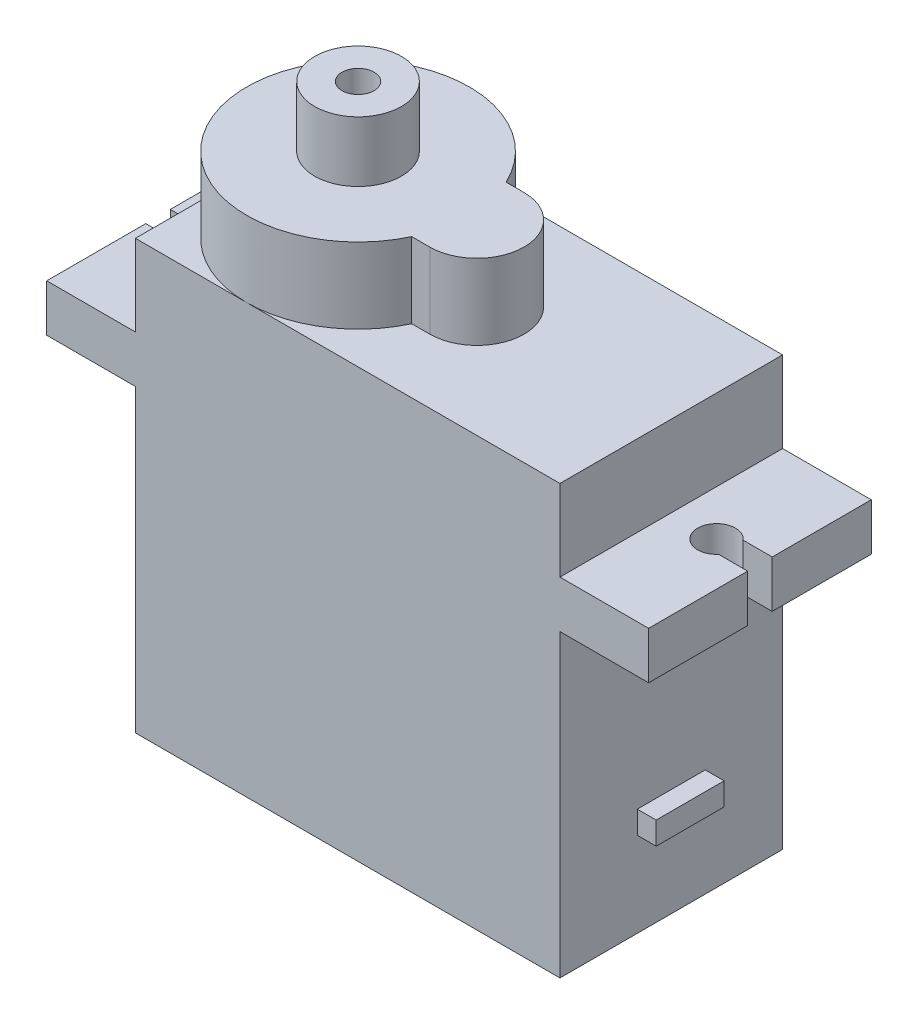
from build123d import *

# Parameters (mm, degrees)
SKETCH1_W           = 22.5
SKETCH1_H           = 11.8
BOSS_EXTRUDE1_DEPTH = 22.7
BOSS_EXTRUDE2_START = 15.9
BOSS_EXTRUDE2_DEPTH = 2.5
BOSS_EXTRUDE3_DEPTH = 4
SKETCH4_R           = 2.3
SKETCH4_R_2         = 0.85
BOSS_EXTRUDE4_DEPTH = 3.2
SKETCH5_W           = 3.6
SKETCH5_H           = 1.2
BOSS_EXTRUDE5_DEPTH = 1


with BuildPart() as part:
    # Sketch1 → Boss-Extrude1 (new body)
    with BuildSketch(Plane(origin=(0, 0, 0), x_dir=(1, 0, 0), z_dir=(0, 1, 0))):
        Rectangle(SKETCH1_W, SKETCH1_H)
    extrude(amount=BOSS_EXTRUDE1_DEPTH)

    # Sketch2 → Boss-Extrude2 (add)
    with BuildSketch(Plane(origin=(0, 0, 0), x_dir=(1, 0, 0), z_dir=(0, 1, 0)).offset(BOSS_EXTRUDE2_START)):
        with BuildLine():
            Line((15.95, 5.9), (11.25, 5.9))
            Line((11.25, 5.9), (11.25, -5.9))
            Line((11.25, -5.9), (15.95, -5.9))
            Line((15.95, -5.9), (15.95, -0.65))
            Line((15.95, -0.65), (14.409934208, -0.65))
            ThreePointArc((14.409934208, -0.65), (12.65, 0), (14.409934208, 0.65))
            Line((14.409934208, 0.65), (15.95, 0.65))
            Line((15.95, 0.65), (15.95, 5.9))
        make_face()
    boss_extrude2 = extrude(amount=BOSS_EXTRUDE2_DEPTH)

    # Mirror1: Boss-Extrude2 across plane
    add(boss_extrude2.mirror(Plane(origin=(0, 0, 0), x_dir=(0, 0, 1), z_dir=(1, 0, 0))))

    # Sketch3 → Boss-Extrude3 (add)
    with BuildSketch(Plane(origin=(0, 22.7, 0), x_dir=(1, 0, 0), z_dir=(0, 1, 0))):
        with BuildLine():
            ThreePointArc((-0.005844314, 2.5), (-11.25, 0), (-0.005844314, -2.5))
            Line((-0.005844314, -2.5), (0.95, -2.5))
            ThreePointArc((0.95, -2.5), (3.45, 0), (0.95, 2.5))
            Line((0.95, 2.5), (-0.005844314, 2.5))
        make_face()
    extrude(amount=BOSS_EXTRUDE3_DEPTH)

    # Sketch4 → Boss-Extrude4 (add)
    with BuildSketch(Plane(origin=(0, 26.7, 0), x_dir=(1, 0, 0), z_dir=(0, 1, 0))):
        with Locations((-5.35, 0)):
            Circle(SKETCH4_R)
        with Locations((-5.35, 0)):
            Circle(SKETCH4_R_2, mode=Mode.SUBTRACT)
    extrude(amount=BOSS_EXTRUDE4_DEPTH)

    # Sketch5 → Boss-Extrude5 (add)
    with BuildSketch(Plane(origin=(11.25, 0, 0), x_dir=(0, 0, -1), z_dir=(1, 0, 0))):
        with Locations((0, 5.1)):
            Rectangle(SKETCH5_W, SKETCH5_H)
    extrude(amount=BOSS_EXTRUDE5_DEPTH)


solid = part.part
